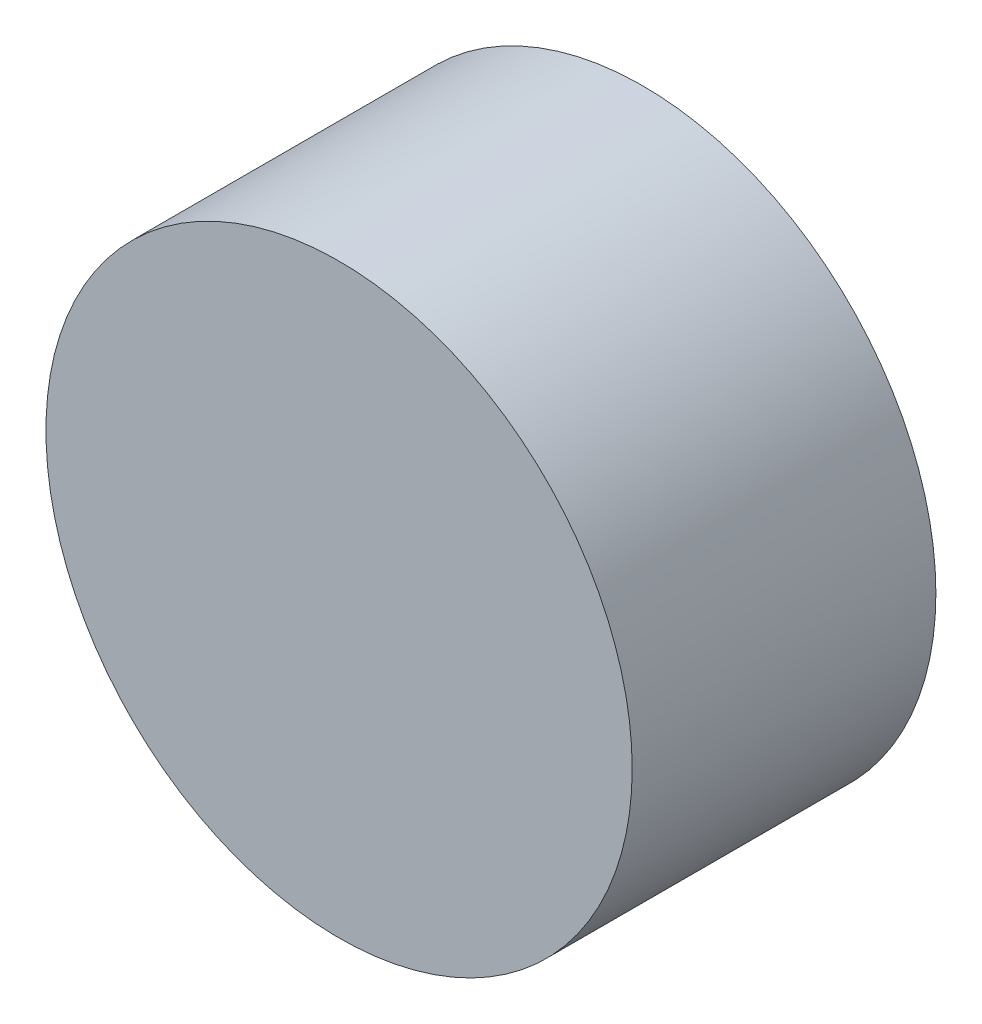
from build123d import *

# Parameters (mm, degrees)
SKETCH1_R           = 4.826
BOSS_EXTRUDE1_DEPTH = 5


with BuildPart() as part:
    # Sketch1 → Boss-Extrude1 (new body)
    with BuildSketch(Plane.XY):
        Circle(SKETCH1_R)
    extrude(amount=BOSS_EXTRUDE1_DEPTH)


solid = part.part
